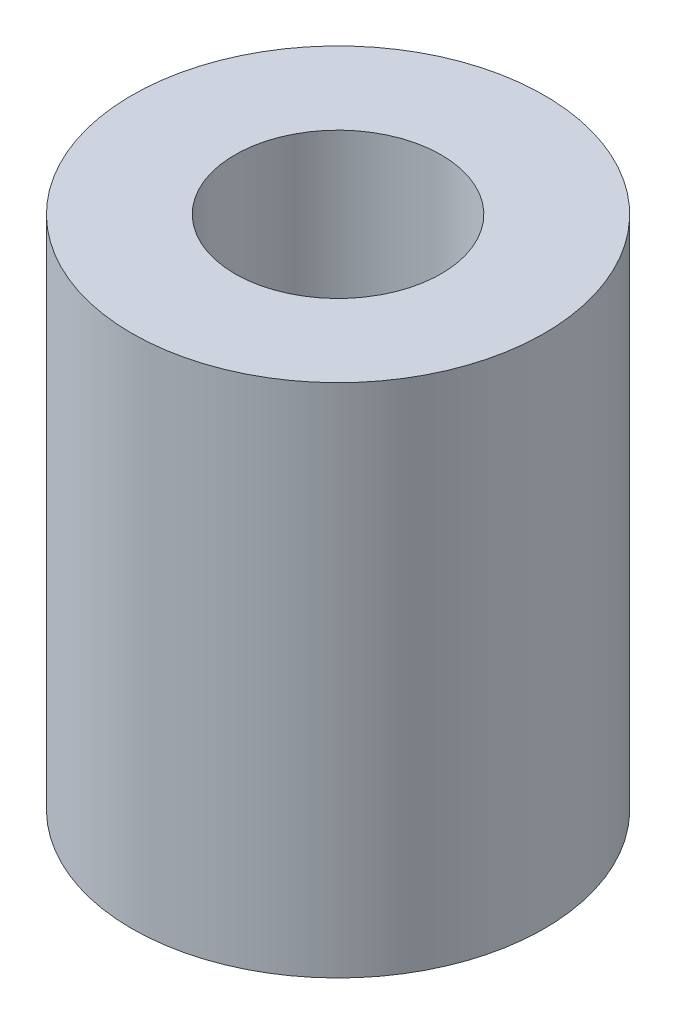
from build123d import *

# Parameters (mm, degrees)
SKETCH1_R           = 4
SKETCH1_R_2         = 2
BOSS_EXTRUDE1_DEPTH = 10


with BuildPart() as part:
    # Sketch1 → Boss-Extrude1 (new body)
    with BuildSketch(Plane(origin=(0, 0, 0), x_dir=(1, 0, 0), z_dir=(0, 1, 0))):
        Circle(SKETCH1_R)
        Circle(SKETCH1_R_2, mode=Mode.SUBTRACT)
    extrude(amount=BOSS_EXTRUDE1_DEPTH)


solid = part.part
